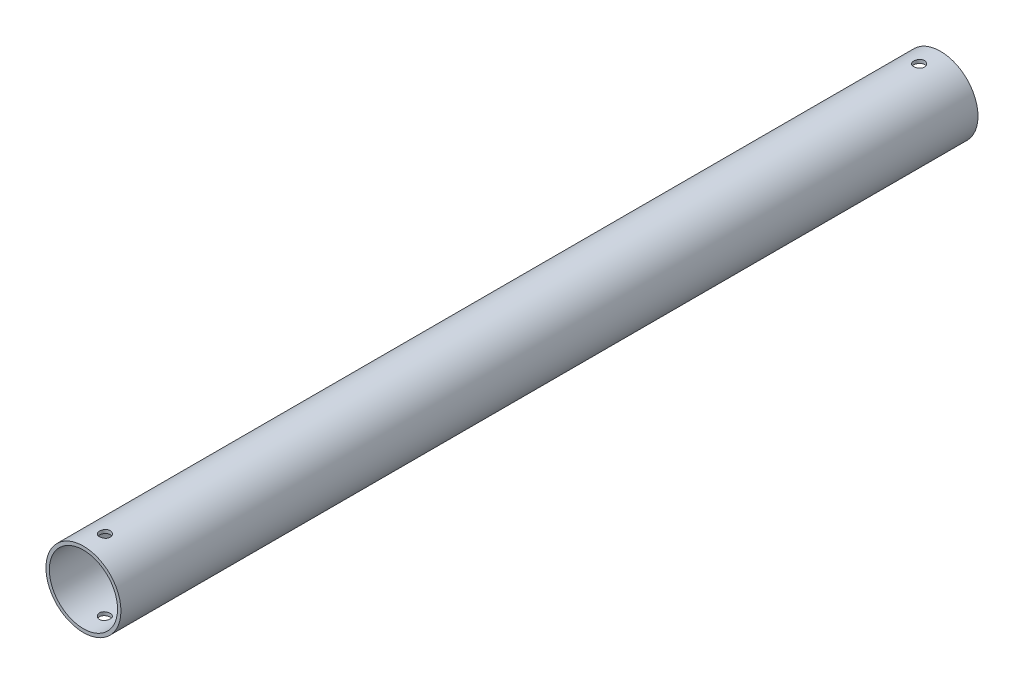
from build123d import *

# Parameters (mm, degrees)
SKETCH1_R                    = 17.5
SKETCH1_R_2                  = 15.9125
BOSS_EXTRUDE1_DEPTH          = 200
ESQUISSE1_R                  = 2.5
ENL_V_MAT_EXTRU_1_DEPTH      = 18.5
ENL_V_MAT_EXTRU_1_DEPTH_BACK = 18.5


with BuildPart() as part:
    # Sketch1 → Boss-Extrude1 (new body, symmetric)
    with BuildSketch(Plane.XY):
        Circle(SKETCH1_R)
        Circle(SKETCH1_R_2, mode=Mode.SUBTRACT)
    extrude(amount=BOSS_EXTRUDE1_DEPTH, both=True)

    # Esquisse1 → Enlèv. mat.-Extru.1 (cut, two sides)
    with BuildSketch(Plane(origin=(0, 0, 0), x_dir=(1, 0, 0), z_dir=(0, 1, 0))) as enl_v_mat_extru_1_sk:
        with Locations((0, 190)):
            Circle(ESQUISSE1_R)
        with Locations((0, -190)):
            Circle(ESQUISSE1_R)
    extrude(amount=ENL_V_MAT_EXTRU_1_DEPTH, mode=Mode.SUBTRACT)
    extrude(enl_v_mat_extru_1_sk.sketch, amount=-ENL_V_MAT_EXTRU_1_DEPTH_BACK, mode=Mode.SUBTRACT)


solid = part.part
